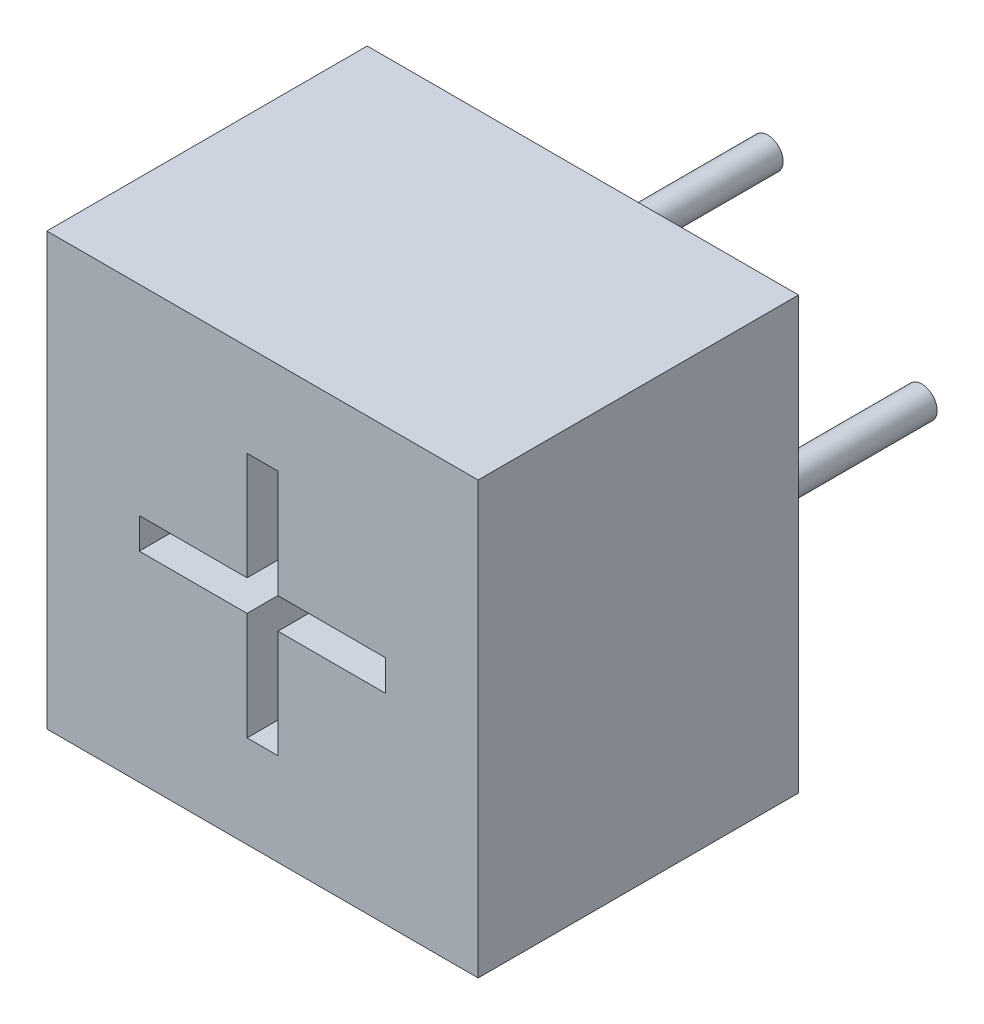
from build123d import *

# Parameters (mm, degrees)
SKETCH1_W           = 7
SKETCH1_H           = 7
BOSS_EXTRUDE1_DEPTH = 5.2
SKETCH2_W           = 4
SKETCH2_H           = 0.5
SKETCH2_W_2         = 0.5
SKETCH2_H_2         = 4
CUT_EXTRUDE1_DEPTH  = 2
SKETCH3_R           = 0.25
BOSS_EXTRUDE2_DEPTH = 3


with BuildPart() as part:
    # Sketch1 → Boss-Extrude1 (new body)
    with BuildSketch(Plane.XY):
        Rectangle(SKETCH1_W, SKETCH1_H)
    extrude(amount=BOSS_EXTRUDE1_DEPTH)

    # Sketch2 → Cut-Extrude1 (cut)
    with BuildSketch(Plane.XY.offset(5.2)):
        Rectangle(SKETCH2_W, SKETCH2_H)
        Rectangle(SKETCH2_W_2, SKETCH2_H_2)
    extrude(amount=-CUT_EXTRUDE1_DEPTH, mode=Mode.SUBTRACT)

    # Sketch3 → Boss-Extrude2 (add)
    with BuildSketch(Plane(origin=(0, 0, 0), x_dir=(-1, 0, 0), z_dir=(0, 0, -1))):
        with Locations((0, 2.25)):
            Circle(SKETCH3_R)
        with Locations((2.5, 0)):
            Circle(SKETCH3_R)
        with Locations((-2.5, 0)):
            Circle(SKETCH3_R)
    extrude(amount=BOSS_EXTRUDE2_DEPTH)


solid = part.part
